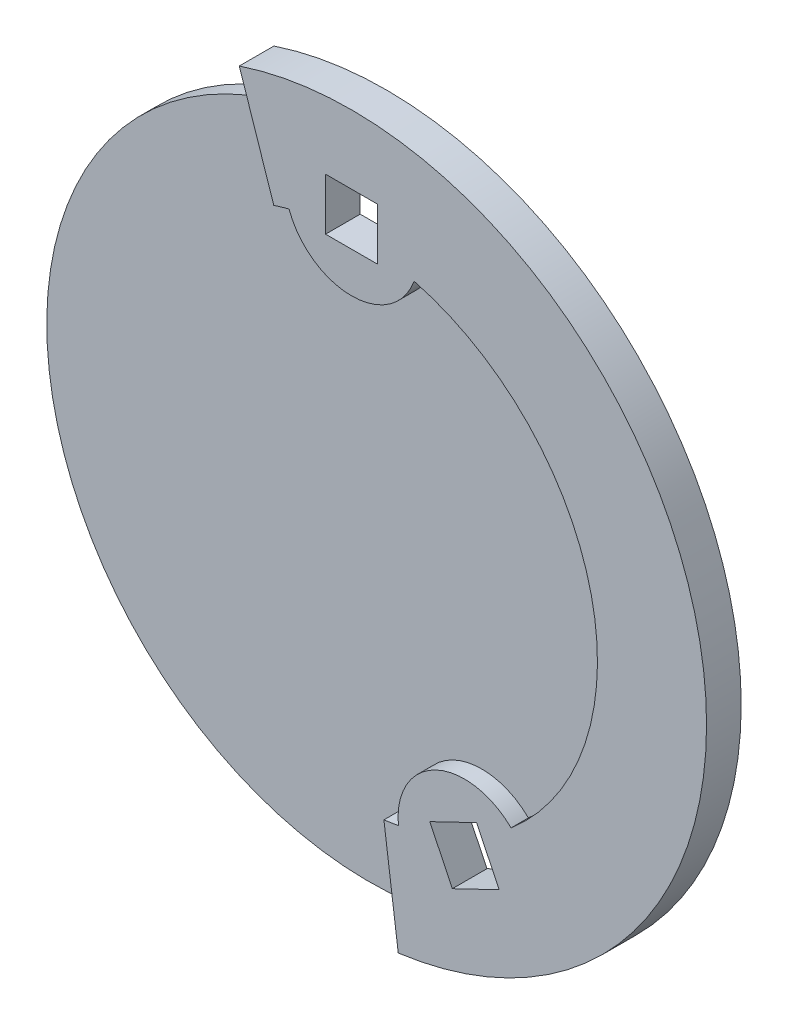
from build123d import *

# Parameters (mm, degrees)
RESSALTO_EXTRUS_O1_DEPTH = 1
RESSALTO_EXTRUS_O2_DEPTH = 1
ESBO_O3_W                = 3
ESBO_O3_H                = 3
CORTE_EXTRUS_O1_DEPTH    = 3


with BuildPart() as part:
    # Esboço1 → Ressalto-extrusão1 (new body)
    with BuildSketch(Plane.XY):
        with BuildLine():
            Line((-5.882044961, 17.645439838), (-6.482899016, 19.447931004))
            ThreePointArc((-6.482899016, 19.447931004), (19.9860222, 4.561679146), (2.597250835, -20.334804845))
            Line((2.597250835, -20.334804845), (2.356530026, -18.450115616))
            ThreePointArc((2.356530026, -18.450115616), (-18.133659167, -4.138889372), (-5.882044961, 17.645439838))
        make_face()
    extrude(amount=RESSALTO_EXTRUS_O1_DEPTH)

    # Esboço2 → Ressalto-extrusão2 (add)
    with BuildSketch(Plane.XY.offset(1)):
        with BuildLine():
            Line((-4.490593465, 13.471249769), (-6.482899016, 19.447931004))
            ThreePointArc((-6.482899016, 19.447931004), (19.974805028, 4.610549218), (2.696693068, -20.321856374))
            Line((2.696693068, -20.321856374), (1.867953247, -14.076602952))
            ThreePointArc((1.867953247, -14.076602952), (2.288152222, -14.014433967), (2.706303705, -13.93972454))
            ThreePointArc((2.706303705, -13.93972454), (4.856795522, -10.085239821), (9.211162742, -10.807149529))
            ThreePointArc((9.211162742, -10.807149529), (13.843976353, 3.159797262), (3.60992442, 13.733479009))
            ThreePointArc((3.60992442, 13.733479009), (0, 11.193771705), (-3.60992442, 13.733479009))
            ThreePointArc((-3.60992442, 13.733479009), (-4.052380602, 13.609489757), (-4.490593465, 13.471249769))
        make_face()
    extrude(amount=RESSALTO_EXTRUS_O2_DEPTH)

    # Esboço3 → Corte-extrusão1 (cut, through all)
    with BuildSketch(Plane(origin=(0, 0, 0), x_dir=(-1, 0, 0), z_dir=(0, 0, -1))):
        Polygon((-7.221547804, -11.538551224), (-4.5186412, -12.840202442), (-5.820292417, -15.543109046), (-8.523199021, -14.241457828), align=None)
        with Locations((0, 15.029187597)):
            Rectangle(ESBO_O3_W, ESBO_O3_H)
    extrude(amount=-CORTE_EXTRUS_O1_DEPTH, mode=Mode.SUBTRACT)


solid = part.part
